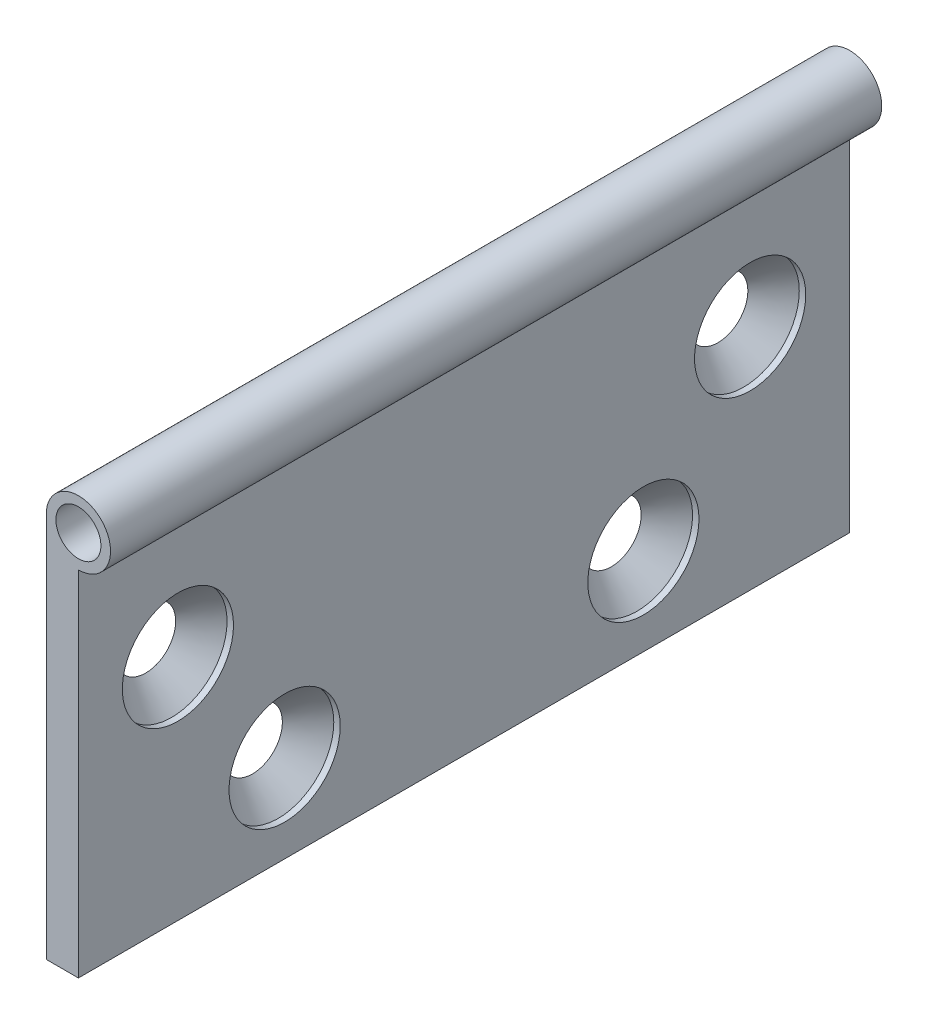
from build123d import *

# Parameters (mm, degrees)
SKETCH2_W                                      = 5
SKETCH2_H                                      = 60
EXTRUDE_THIN1_DEPTH                            = 60
SKETCH3_R                                      = 5
SKETCH4_R                                      = 3.5
CUT_EXTRUDE1_DEPTH                             = 137.839321834
CSK_FOR_M8_FLAT_HEAD_MACHINE_SCREW1_AT_2_COUNT = 2
CSK_FOR_M8_FLAT_HEAD_MACHINE_SCREW1_AT_2_PITCH = 27.483528756


with BuildPart() as part:
    # Sketch2 → Extrude-Thin1 (new, symmetric)
    with BuildSketch(Plane.XY):
        with Locations((2.5, 30)):
            Rectangle(SKETCH2_W, SKETCH2_H)
    extrude(amount=EXTRUDE_THIN1_DEPTH, both=True)

    # Sweep11: sweep along a curve in space
    with BuildLine() as sweep11_path:
        Line((5, 60, 60), (5, 60, -60))
    # Sketch3 → Sweep11 (sweep)
    with BuildSketch(Plane.XY.offset(60)):
        with Locations((5, 60)):
            Circle(SKETCH3_R)
    sweep(path=sweep11_path.line)

    # Sketch4 → Cut-Extrude1 (cut, through all)
    with BuildSketch(Plane.XY.offset(60)):
        with Locations((5, 60)):
            Circle(SKETCH4_R)
    extrude(amount=-CUT_EXTRUDE1_DEPTH, mode=Mode.SUBTRACT)

    # Sketch6 → CSK for M8 Flat Head Machine Screw1 (revolve, cut)
    with BuildSketch(Plane(origin=(5, 35.505970187, 44.516987054), x_dir=(0, 0, -1), z_dir=(0, 1, 0))):
        Polygon((0, 0), (0, 5), (4.5, 5), (4.5, 5.15), (8.65, 1), (8.65, 0), align=None)
    csk_for_m8_flat_head_machine_screw1 = revolve(axis=Axis((11.35, 35.505970187, 44.516987054), (-1, 0, 0)), mode=Mode.SUBTRACT)

    # CSK for M8 Flat Head Machine Screw1 at 2: CSK for M8 Flat Head Machine Screw1 ×2
    with Locations(*[Vector(0, -0.7968641919109715, -0.604158472298514) * (i * CSK_FOR_M8_FLAT_HEAD_MACHINE_SCREW1_AT_2_PITCH) for i in range(1, CSK_FOR_M8_FLAT_HEAD_MACHINE_SCREW1_AT_2_COUNT)]):
        add(csk_for_m8_flat_head_machine_screw1, mode=Mode.SUBTRACT)

    # Mirror1: CSK for M8 Flat Head Machine Screw1 across plane
    add(csk_for_m8_flat_head_machine_screw1.mirror(Plane.XY), mode=Mode.SUBTRACT)

    # Mirror1 copy 1 sketch → Mirror1 copy 1 (revolve, cut)
    with BuildSketch(Plane(origin=(5, 13.605330254, -27.912580307), x_dir=(0, 0, 1), z_dir=(0, 1, 0))):
        Polygon((0, 0), (0, -5), (4.5, -5), (4.5, -5.15), (8.65, -1), (8.65, 0), align=None)
    revolve(axis=Axis((11.35, 13.605330254, -27.912580307), (1, 0, 0)), mode=Mode.SUBTRACT)


solid = part.part
